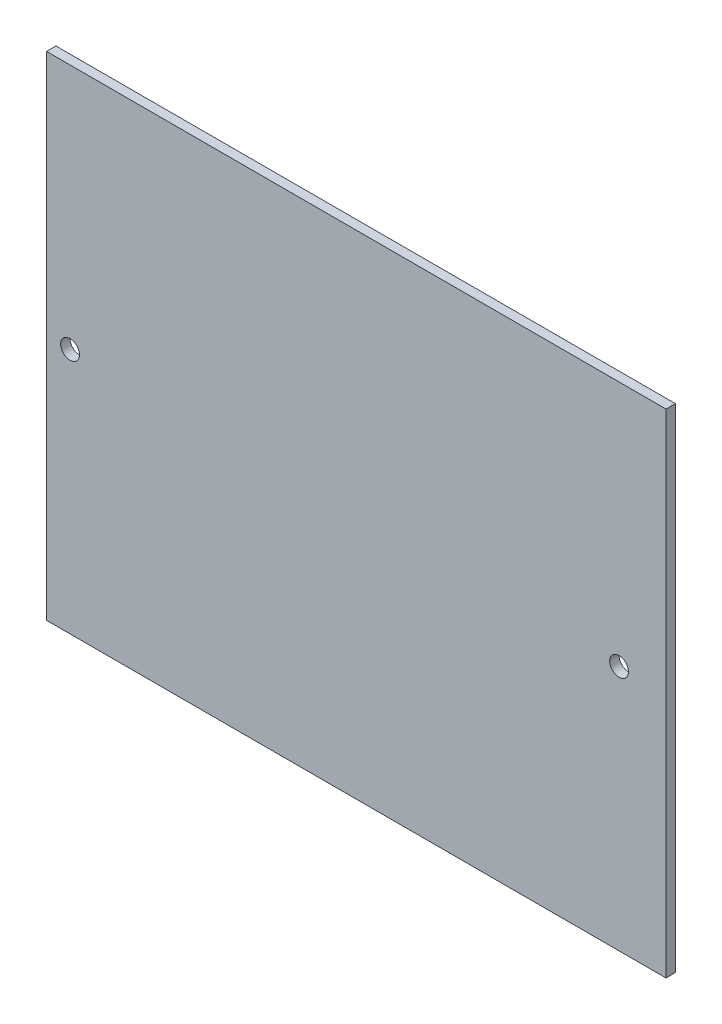
from build123d import *

# Parameters (mm, degrees)
SKETCH1_W           = 132
SKETCH1_H           = 105
BOSS_EXTRUDE1_DEPTH = 2
SKETCH2_R           = 2
CUT_EXTRUDE1_DEPTH  = 10
SKETCH3_R           = 2
CUT_EXTRUDE2_DEPTH  = 10


with BuildPart() as part:
    # Sketch1 → Boss-Extrude1 (new body)
    with BuildSketch(Plane.XY):
        with Locations((140.120120189, 13.357893544)):
            Rectangle(SKETCH1_W, SKETCH1_H)
    extrude(amount=BOSS_EXTRUDE1_DEPTH)

    # Sketch2 → Cut-Extrude1 (cut)
    with BuildSketch(Plane(origin=(0, 0, 0), x_dir=(-1, 0, 0), z_dir=(0, 0, -1))):
        with Locations((-196.120120189, 13.357893544)):
            Circle(SKETCH2_R)
    extrude(amount=-CUT_EXTRUDE1_DEPTH, mode=Mode.SUBTRACT)

    # Sketch3 → Cut-Extrude2 (cut)
    with BuildSketch(Plane(origin=(0, 0, 0), x_dir=(-1, 0, 0), z_dir=(0, 0, -1))):
        with Locations((-79.120120189, 13.357893544)):
            Circle(SKETCH3_R)
    extrude(amount=-CUT_EXTRUDE2_DEPTH, mode=Mode.SUBTRACT)


solid = part.part
